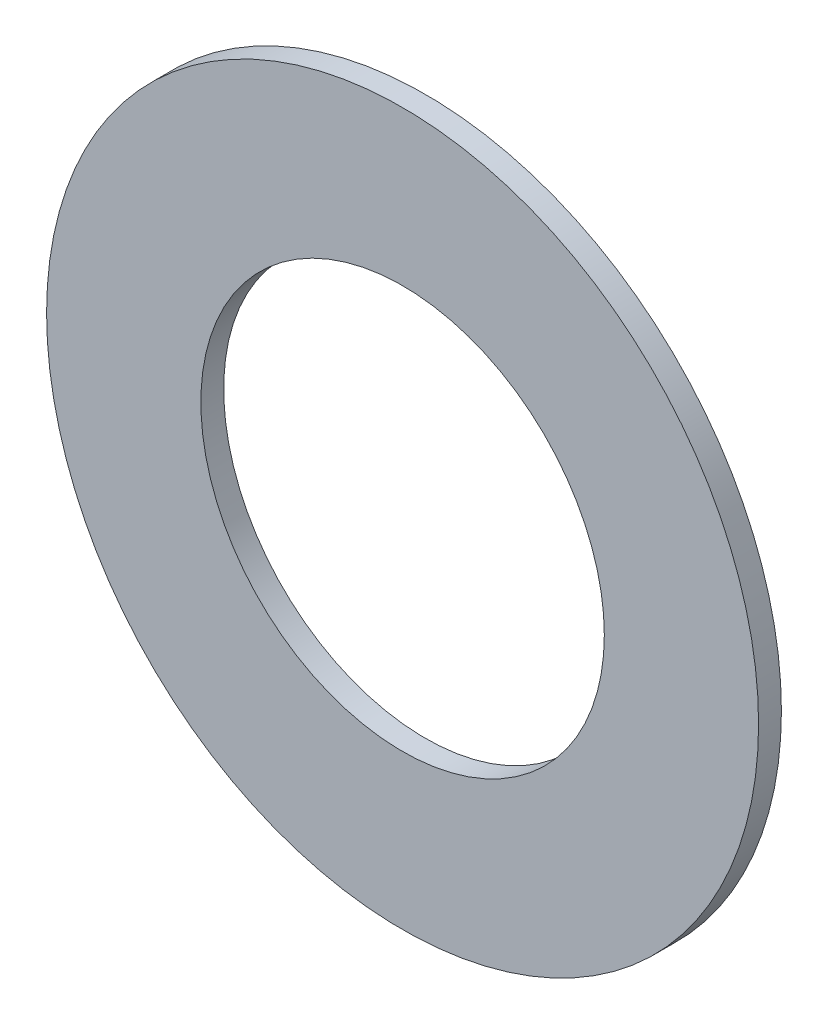
from build123d import *

# Parameters (mm, degrees)
SKETCH1_R           = 49.53
SKETCH1_R_2         = 28.067
BOSS_EXTRUDE1_DEPTH = 3.175


with BuildPart() as part:
    # Sketch1 → Boss-Extrude1 (new body)
    with BuildSketch(Plane.XY):
        Circle(SKETCH1_R)
        Circle(SKETCH1_R_2, mode=Mode.SUBTRACT)
    extrude(amount=BOSS_EXTRUDE1_DEPTH)


solid = part.part
